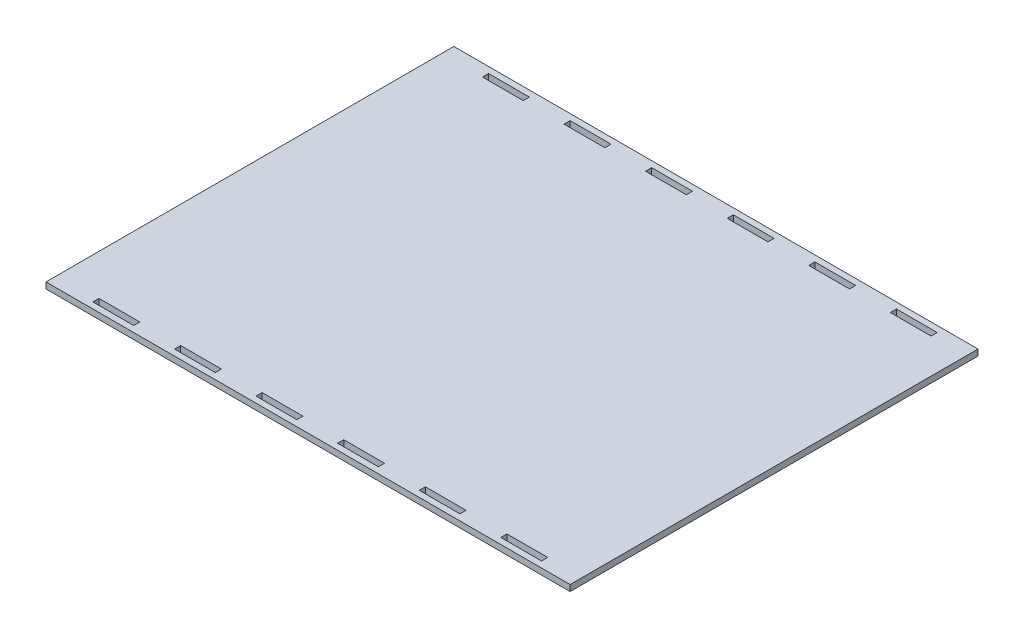
from build123d import *

# Parameters (mm, degrees)
ESQUISSE1_W        = 257
ESQUISSE1_H        = 200
ESQUISSE1_W_2      = 20
ESQUISSE1_H_2      = 3
BOSS_EXTRU_1_DEPTH = 3


with BuildPart() as part:
    # Esquisse1 → Boss.-Extru.1 (new body)
    with BuildSketch(Plane(origin=(0, 0, 0), x_dir=(1, 0, 0), z_dir=(0, 1, 0))):
        Rectangle(ESQUISSE1_W, ESQUISSE1_H)
        with Locations((-58.5, -95.5)):
            Rectangle(ESQUISSE1_W_2, ESQUISSE1_H_2, mode=Mode.SUBTRACT)
        with Locations((-98.5, -95.5)):
            Rectangle(ESQUISSE1_W_2, ESQUISSE1_H_2, mode=Mode.SUBTRACT)
        with Locations((-18.5, -95.5)):
            Rectangle(ESQUISSE1_W_2, ESQUISSE1_H_2, mode=Mode.SUBTRACT)
        with Locations((21.5, -95.5)):
            Rectangle(ESQUISSE1_W_2, ESQUISSE1_H_2, mode=Mode.SUBTRACT)
        with Locations((61.5, -95.5)):
            Rectangle(ESQUISSE1_W_2, ESQUISSE1_H_2, mode=Mode.SUBTRACT)
        with Locations((101.5, -95.5)):
            Rectangle(ESQUISSE1_W_2, ESQUISSE1_H_2, mode=Mode.SUBTRACT)
        with Locations((101.5, 95.5)):
            Rectangle(ESQUISSE1_W_2, ESQUISSE1_H_2, mode=Mode.SUBTRACT)
        with Locations((61.5, 95.5)):
            Rectangle(ESQUISSE1_W_2, ESQUISSE1_H_2, mode=Mode.SUBTRACT)
        with Locations((21.5, 95.5)):
            Rectangle(ESQUISSE1_W_2, ESQUISSE1_H_2, mode=Mode.SUBTRACT)
        with Locations((-18.5, 95.5)):
            Rectangle(ESQUISSE1_W_2, ESQUISSE1_H_2, mode=Mode.SUBTRACT)
        with Locations((-58.5, 95.5)):
            Rectangle(ESQUISSE1_W_2, ESQUISSE1_H_2, mode=Mode.SUBTRACT)
        with Locations((-98.5, 95.5)):
            Rectangle(ESQUISSE1_W_2, ESQUISSE1_H_2, mode=Mode.SUBTRACT)
    extrude(amount=BOSS_EXTRU_1_DEPTH)


solid = part.part
